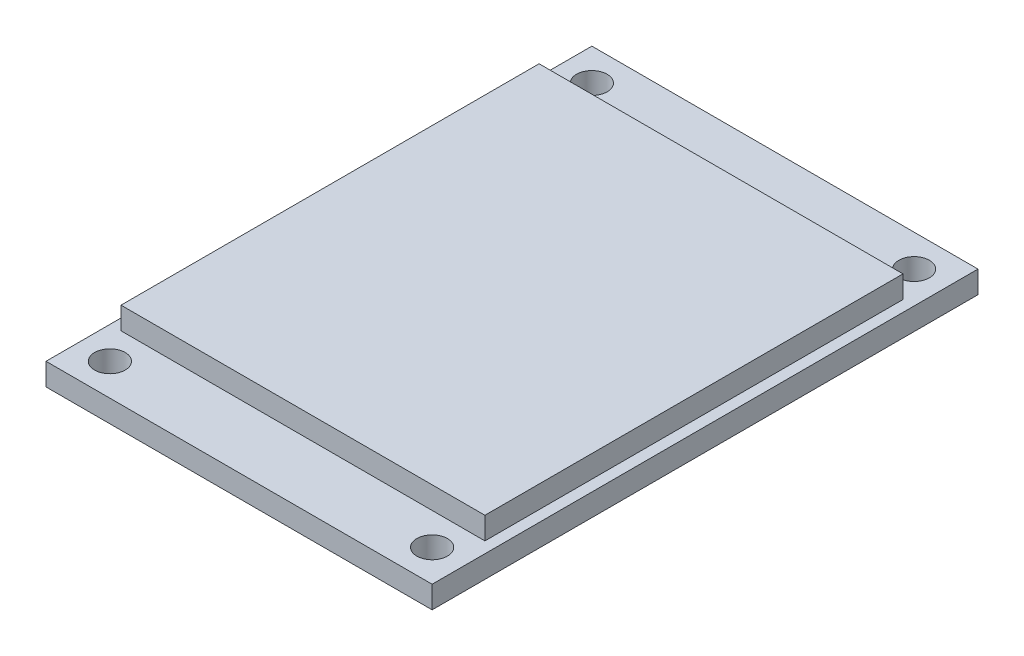
from build123d import *

# Parameters (mm, degrees)
SKETCH_1_W          = 27.8
SKETCH_1_H          = 39.3
EXTRUDE_1_DEPTH     = 1.6
SKETCH_2_R          = 1.1
CUT_EXTRUDE_1_DEPTH = 1.6
SKETCH_3_W          = 26.2
SKETCH_3_H          = 30.1
EXTRUDE_2_DEPTH     = 1.6
SKETCH_4_W          = 17.78
SKETCH_4_H          = 2.54
EXTRUDE_3_DEPTH     = 2.54


with BuildPart() as part:
    # 草图1 → 凸台-拉伸1 (new body)
    with BuildSketch(Plane(origin=(0, 0, 0), x_dir=(1, 0, 0), z_dir=(0, 1, 0))):
        Rectangle(SKETCH_1_W, SKETCH_1_H)
    extrude(amount=EXTRUDE_1_DEPTH)

    # 草图2 → 切除-拉伸1 (cut)
    with BuildSketch(Plane(origin=(0, 1.6, 0), x_dir=(1, 0, 0), z_dir=(0, 1, 0))):
        with Locations((-11.6, 17.35)):
            Circle(SKETCH_2_R)
        with Locations((11.6, 17.35)):
            Circle(SKETCH_2_R)
        with Locations((-11.6, -17.35)):
            Circle(SKETCH_2_R)
        with Locations((11.6, -17.35)):
            Circle(SKETCH_2_R)
    extrude(amount=-CUT_EXTRUDE_1_DEPTH, mode=Mode.SUBTRACT)

    # 草图3 → 凸台-拉伸2 (add)
    with BuildSketch(Plane(origin=(0, 1.6, 0), x_dir=(1, 0, 0), z_dir=(0, 1, 0))):
        Rectangle(SKETCH_3_W, SKETCH_3_H)
    extrude(amount=EXTRUDE_2_DEPTH)

    # 草图4 → 凸台-拉伸3 (add)
    with BuildSketch(Plane.XZ):
        with Locations((0, -17.68)):
            Rectangle(SKETCH_4_W, SKETCH_4_H)
    extrude(amount=EXTRUDE_3_DEPTH)


solid = part.part
